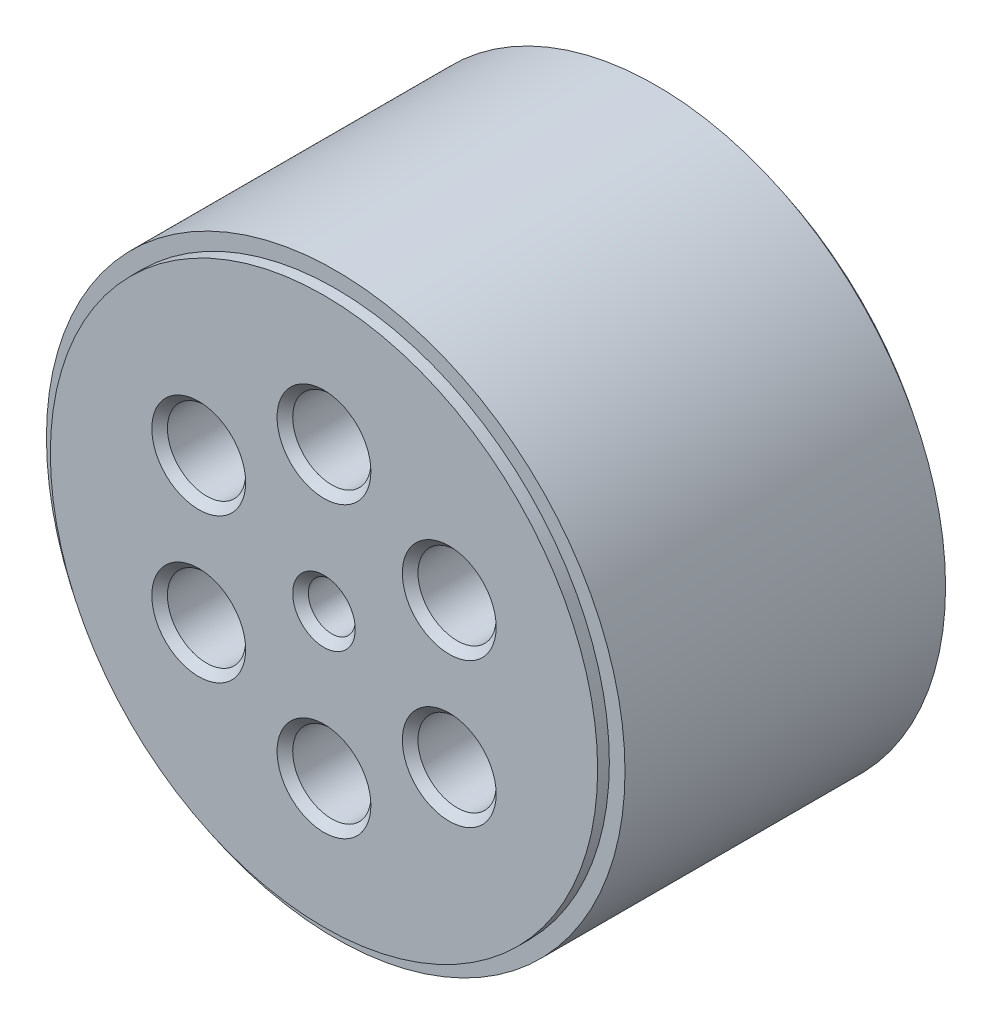
from build123d import *

# Parameters (mm, degrees)
ESQUISSE1_R             = 34
ESQUISSE1_R_2           = 3
ESQUISSE1_R_3           = 5
BOSS_EXTRU_1_DEPTH      = 22
ESQUISSE2_R             = 37
ESQUISSE2_R_2           = 34
BOSS_EXTRU_2_DEPTH      = 44
ESQUISSE2_3_R           = 37
ESQUISSE2_3_R_2         = 34
ENL_V_MAT_EXTRU_1_DEPTH = 1.5
ESQUISSE3_R             = 35
ESQUISSE3_R_2           = 34
BOSS_EXTRU_3_DEPTH      = 1.5
CHANFREIN1_SIZE         = 1
ESQUISSE4_R             = 29
ENL_V_MAT_EXTRU_2_DEPTH = 32


with BuildPart() as part:
    # Esquisse1 → Boss.-Extru.1 (new body, symmetric)
    with BuildSketch(Plane.XY):
        Circle(ESQUISSE1_R)
        Circle(ESQUISSE1_R_2, mode=Mode.SUBTRACT)
        with Locations((0, 18.5)):
            Circle(ESQUISSE1_R_3, mode=Mode.SUBTRACT)
        with Locations((16.02146997, 9.25)):
            Circle(ESQUISSE1_R_3, mode=Mode.SUBTRACT)
        with Locations((16.02146997, -9.25)):
            Circle(ESQUISSE1_R_3, mode=Mode.SUBTRACT)
        with Locations((0, -18.5)):
            Circle(ESQUISSE1_R_3, mode=Mode.SUBTRACT)
        with Locations((-16.02146997, -9.25)):
            Circle(ESQUISSE1_R_3, mode=Mode.SUBTRACT)
        with Locations((-16.02146997, 9.25)):
            Circle(ESQUISSE1_R_3, mode=Mode.SUBTRACT)
    extrude(amount=BOSS_EXTRU_1_DEPTH, both=True)

    # Esquisse2 → Boss.-Extru.2 (add)
    with BuildSketch(Plane.XY.offset(22)):
        Circle(ESQUISSE2_R)
        Circle(ESQUISSE2_R_2, mode=Mode.SUBTRACT)
    extrude(amount=-BOSS_EXTRU_2_DEPTH)

    # Esquisse2_3 → Enl_v. mat.-Extru.1 (cut)
    with BuildSketch(Plane.XY.offset(22)):
        Circle(ESQUISSE2_3_R)
        Circle(ESQUISSE2_3_R_2, mode=Mode.SUBTRACT)
    enl_v_mat_extru_1 = extrude(amount=-ENL_V_MAT_EXTRU_1_DEPTH, mode=Mode.SUBTRACT)

    # Sym_trie1: Enl_v. mat.-Extru.1 across plane
    add(enl_v_mat_extru_1.mirror(Plane.XY), mode=Mode.SUBTRACT)

    # Esquisse3 → Boss.-Extru.3 (add)
    with BuildSketch(Plane.XY.offset(22)):
        Circle(ESQUISSE3_R)
        Circle(ESQUISSE3_R_2, mode=Mode.SUBTRACT)
    boss_extru_3 = extrude(amount=-BOSS_EXTRU_3_DEPTH)

    # Sym_trie2: Boss.-Extru.3 across plane
    add(boss_extru_3.mirror(Plane.XY))

    # Chanfrein1
    chanfrein1_edges = [part.edges().sort_by_distance(p)[0] for p in [
        (11.02146997, 9.25, -22),
        (11.02146997, 9.25, 22),
        (11.02146997, -9.25, -22),
        (11.02146997, -9.25, 22),
        (-5, -18.5, -22),
        (-5, -18.5, 22),
        (-21.02146997, -9.25, -22),
        (-21.02146997, -9.25, 22),
        (-21.02146997, 9.25, -22),
        (-21.02146997, 9.25, 22),
        (-3, 0, -22),
        (-3, 0, 22),
        (-5, 18.5, -22),
        (-5, 18.5, 22),
    ]]
    chamfer(chanfrein1_edges, length=CHANFREIN1_SIZE)

    # Esquisse4 → Enl_v. mat.-Extru.2 (cut)
    with BuildSketch(Plane(origin=(0, 0, -22), x_dir=(-1, 0, 0), z_dir=(0, 0, -1))):
        Circle(ESQUISSE4_R)
    extrude(amount=-ENL_V_MAT_EXTRU_2_DEPTH, mode=Mode.SUBTRACT)


solid = part.part
